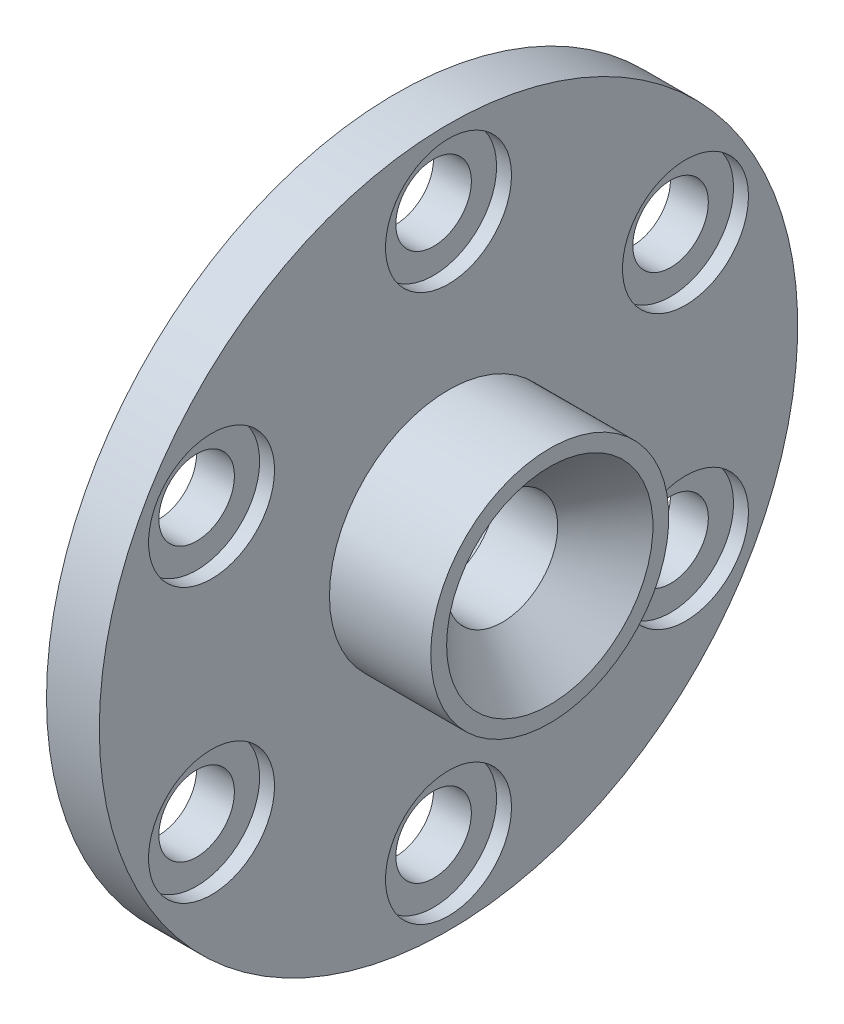
from build123d import *

# Parameters (mm, degrees)
SKETCH5_R          = 2.38125
CUT_EXTRUDE1_DEPTH = 24.019799782
SKETCH6_R          = 3.96875
CUT_EXTRUDE2_DEPTH = 0.9398


with BuildPart() as part:
    # Sketch3 → Revolve1 (revolve)
    with BuildSketch(Plane.XY):
        Polygon((13.312399842, 22.00099994), (16.639799842, 22.00099994), (16.639799842, 7.499999986), (18.039799836, 7.499999986), (23.019799782, 7.499999986), (23.019799782, 6.499999954), (20.019799813, 3.499999985), (16.119799866, 3.499999985), (16.119799866, 4.000000001), (13.639799746, 4.000000001), (13.639799746, 12.269749908), (13.312399842, 12.269749908), align=None)
    revolve(axis=Axis((0, 0, 0), (1, 0, 0)))

    # Sketch5 → Cut-Extrude1 (cut, through all)
    with BuildSketch(Plane(origin=(0, 0, 0), x_dir=(0, 0, -1), z_dir=(1, 0, 0))):
        with Locations((-14.928978871, 8.61924997)):
            Circle(SKETCH5_R)
        with Locations((0, 17.23849994)):
            Circle(SKETCH5_R)
        with Locations((14.928978871, 8.61924997)):
            Circle(SKETCH5_R)
        with Locations((14.928978871, -8.61924997)):
            Circle(SKETCH5_R)
        with Locations((0, -17.23849994)):
            Circle(SKETCH5_R)
        with Locations((-14.928978871, -8.61924997)):
            Circle(SKETCH5_R)
    extrude(amount=CUT_EXTRUDE1_DEPTH, mode=Mode.SUBTRACT)

    # Sketch6 → Cut-Extrude2 (cut)
    with BuildSketch(Plane(origin=(16.639799842, 0, 0), x_dir=(0, 0, -1), z_dir=(1, 0, 0))):
        with Locations((0, 17.23849994)):
            Circle(SKETCH6_R)
        with Locations((14.928978871, 8.61924997)):
            Circle(SKETCH6_R)
        with Locations((14.928978871, -8.61924997)):
            Circle(SKETCH6_R)
        with Locations((0, -17.23849994)):
            Circle(SKETCH6_R)
        with Locations((-14.928978871, -8.61924997)):
            Circle(SKETCH6_R)
        with Locations((-14.928978871, 8.61924997)):
            Circle(SKETCH6_R)
    extrude(amount=-CUT_EXTRUDE2_DEPTH, mode=Mode.SUBTRACT)


solid = part.part
